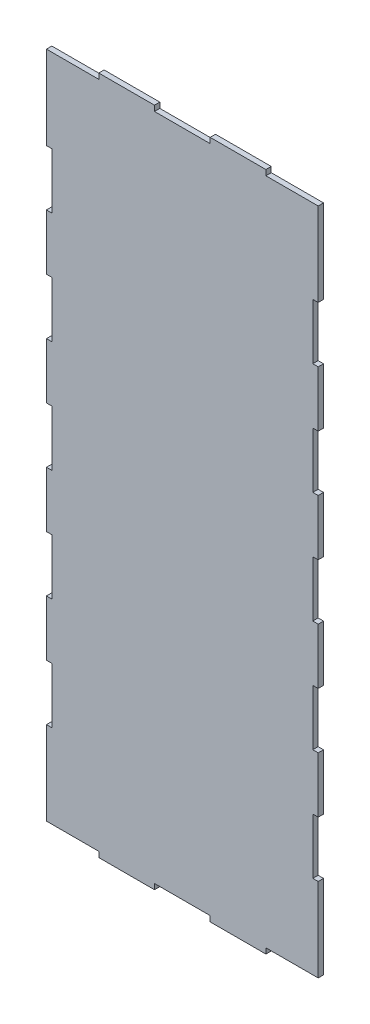
from build123d import *

# Parameters (mm, degrees)
BOSS_EXTRUDE1_DEPTH = 50
SCALE1_SCALE        = 0.04


with BuildPart() as part:
    # Sketch1 → Boss-Extrude1 (new body)
    with BuildSketch(Plane.XY):
        Polygon((0, 6238.869420035), (0, 5457.819420035), (50.8, 5457.819420035), (50.8, 4937.119420035), (0, 4937.119420035), (0, 4416.419420035), (50.8, 4416.419420035), (50.8, 3895.719420035), (0, 3895.719420035), (0, 3375.019420035), (50.8, 3375.019420035), (50.8, 2854.319420035), (0, 2854.319420035), (0, 2333.619420035), (50.8, 2333.619420035), (50.8, 1812.919420035), (0, 1812.919420035), (0, 1292.219420035), (50.8, 1292.219420035), (50.8, 771.519420035), (0, 771.519420035), (0, 250.819420035), (0, -9.530579965), (488.95, -9.530579965), (488.95, -60.330579965), (1009.65, -60.330579965), (1009.65, -9.530579965), (1530.35, -9.530579965), (1530.35, -60.330579965), (2051.05, -60.330579965), (2051.05, -9.530579965), (2540, -9.530579965), (2540, 771.519420035), (2489.2, 771.519420035), (2489.2, 1292.219420035), (2540, 1292.219420035), (2540, 1812.919420035), (2489.2, 1812.919420035), (2489.2, 2333.619420035), (2540, 2333.619420035), (2540, 2854.319420035), (2489.2, 2854.319420035), (2489.2, 3375.019420035), (2540, 3375.019420035), (2540, 3895.719420035), (2489.2, 3895.719420035), (2489.2, 4416.419420035), (2540, 4416.419420035), (2540, 4937.119420035), (2489.2, 4937.119420035), (2489.2, 5457.819420035), (2540, 5457.819420035), (2540, 5978.519420035), (2540, 6238.869420035), (2051.05, 6238.869420035), (2051.05, 6289.669420035), (1530.35, 6289.669420035), (1530.35, 6238.869420035), (1009.65, 6238.869420035), (1009.65, 6289.669420035), (488.95, 6289.669420035), (488.95, 6238.869420035), align=None)
    extrude(amount=BOSS_EXTRUDE1_DEPTH)


with BuildPart() as part_1:
    # Scale1: scaled about (1270, 3114.669420035, 25)
    add(part.part.scale(SCALE1_SCALE).moved(Location((1219.2, 2990.082643234, 24))))


solid = part_1.part
